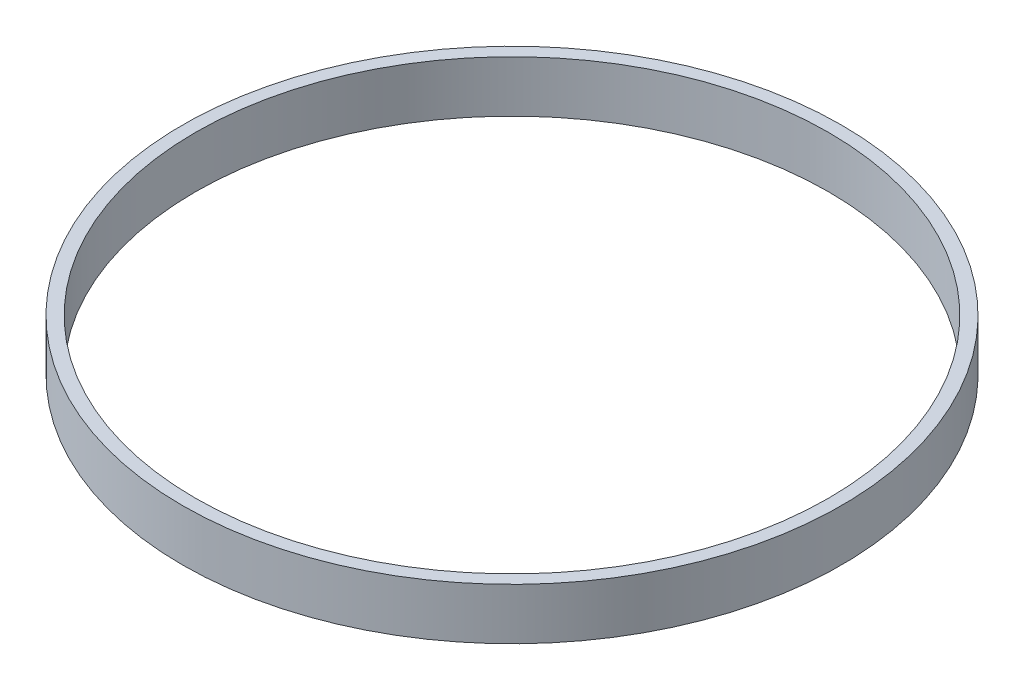
from build123d import *

# Parameters (mm, degrees)
SKETCH1_R           = 81.3308
SKETCH1_R_2         = 78.1558
BOSS_EXTRUDE1_DEPTH = 12.7


with BuildPart() as part:
    # Sketch1 → Boss-Extrude1 (new body)
    with BuildSketch(Plane(origin=(0, 0, 0), x_dir=(1, 0, 0), z_dir=(0, 1, 0))):
        Circle(SKETCH1_R)
        Circle(SKETCH1_R_2, mode=Mode.SUBTRACT)
    extrude(amount=BOSS_EXTRUDE1_DEPTH)


solid = part.part
